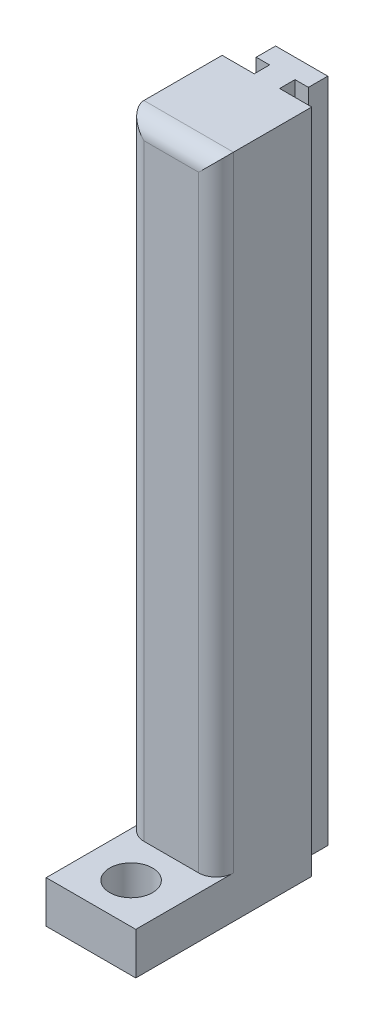
from build123d import *

# Parameters (mm, degrees)
SKETCH1_W               = 8.5
SKETCH1_H               = 20
BOSS_EXTRUDE1_DEPTH     = 63.246
SKETCH2_W               = 8.5
SKETCH2_H               = 7.62
CUT_EXTRUDE1_DEPTH      = 59.246
CUT_EXTRUDE2_DEPTH      = 5.334
CUT_EXTRUDE2_DEPTH_BACK = 79.922
SKETCH5_R               = 2.032
CUT_EXTRUDE3_DEPTH      = 79.922
FILLET1_R               = 1.651


with BuildPart() as part:
    # Sketch1 → Boss-Extrude1 (new body)
    with BuildSketch(Plane(origin=(0, 0, 0), x_dir=(1, 0, 0), z_dir=(0, 1, 0))):
        Rectangle(SKETCH1_W, SKETCH1_H)
    extrude(amount=BOSS_EXTRUDE1_DEPTH)

    # Sketch2 → Cut-Extrude1 (cut)
    with BuildSketch(Plane(origin=(0, 63.246, 0), x_dir=(1, 0, 0), z_dir=(0, 1, 0))):
        with Locations((0, -6.19)):
            Rectangle(SKETCH2_W, SKETCH2_H)
    extrude(amount=-CUT_EXTRUDE1_DEPTH, mode=Mode.SUBTRACT)

    # Sketch4 → Cut-Extrude2 (cut, two sides)
    with BuildSketch(Plane(origin=(0, 63.246, 0), x_dir=(1, 0, 0), z_dir=(0, 1, 0))) as cut_extrude2_sk:
        Polygon((-1.2065, 6.698), (-4.25, 6.698), (-4.25, 10), (-2.4765, 10), (-2.4765, 8.1585), (-1.2065, 8.1585), align=None)
        Polygon((1.2065, 6.698), (4.25, 6.698), (4.25, 10), (2.4765, 10), (2.4765, 8.1585), (1.2065, 8.1585), align=None)
    extrude(amount=CUT_EXTRUDE2_DEPTH, mode=Mode.SUBTRACT)
    extrude(cut_extrude2_sk.sketch, amount=-CUT_EXTRUDE2_DEPTH_BACK, mode=Mode.SUBTRACT)

    # Sketch5 → Cut-Extrude3 (cut)
    with BuildSketch(Plane(origin=(0, 4, 0), x_dir=(1, 0, 0), z_dir=(0, 1, 0))):
        with Locations((0, -6.19)):
            Circle(SKETCH5_R)
    extrude(amount=-CUT_EXTRUDE3_DEPTH, mode=Mode.SUBTRACT)

    # Fillet1
    fillet1_edges = [part.edges().sort_by_distance(p)[0] for p in [
        (4.25, 33.623, 2.38),
        (-4.25, 33.623, 2.38),
        (0, 63.246, 2.38),
    ]]
    fillet(fillet1_edges, radius=FILLET1_R)


solid = part.part
